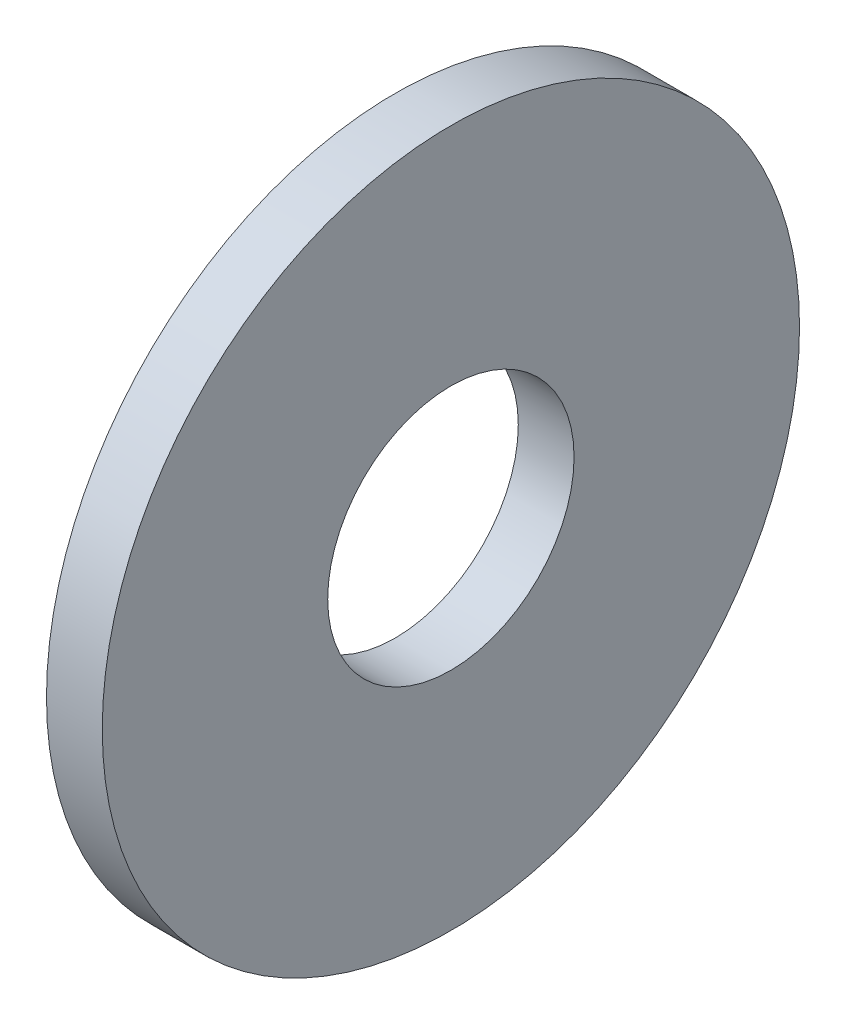
from build123d import *

# Parameters (mm, degrees)
SKETCH1_W = 1.2
SKETCH1_H = 4.85


with BuildPart() as part:
    # Sketch1 → Base-Revolve (revolve)
    with BuildSketch(Plane.XY):
        with Locations((-0.6, 5.075)):
            Rectangle(SKETCH1_W, SKETCH1_H)
    revolve(axis=Axis((-34.925, 0, 0), (1, 0, 0)))


solid = part.part
